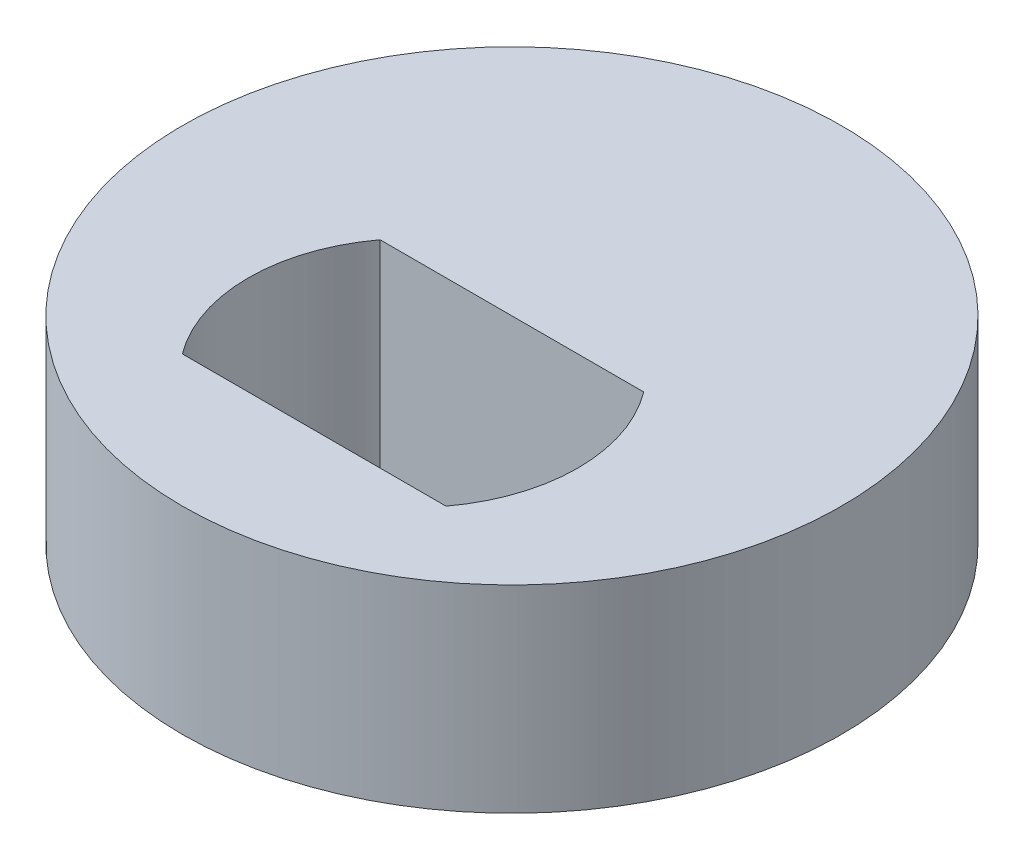
from build123d import *

# Parameters (mm, degrees)
SKETCH1_R           = 5
BOSS_EXTRUDE1_DEPTH = 3


with BuildPart() as part:
    # Sketch1 → Boss-Extrude1 (new body)
    with BuildSketch(Plane(origin=(0, 0, 0), x_dir=(1, 0, 0), z_dir=(0, 1, 0))):
        Circle(SKETCH1_R)
        with BuildLine():
            Line((-2, 0), (2, 0))
            ThreePointArc((2, 0), (2.5, -1.5), (2, -3))
            Line((2, -3), (-2, -3))
            ThreePointArc((-2, -3), (-2.5, -1.5), (-2, 0))
        make_face(mode=Mode.SUBTRACT)
    extrude(amount=BOSS_EXTRUDE1_DEPTH)


solid = part.part
